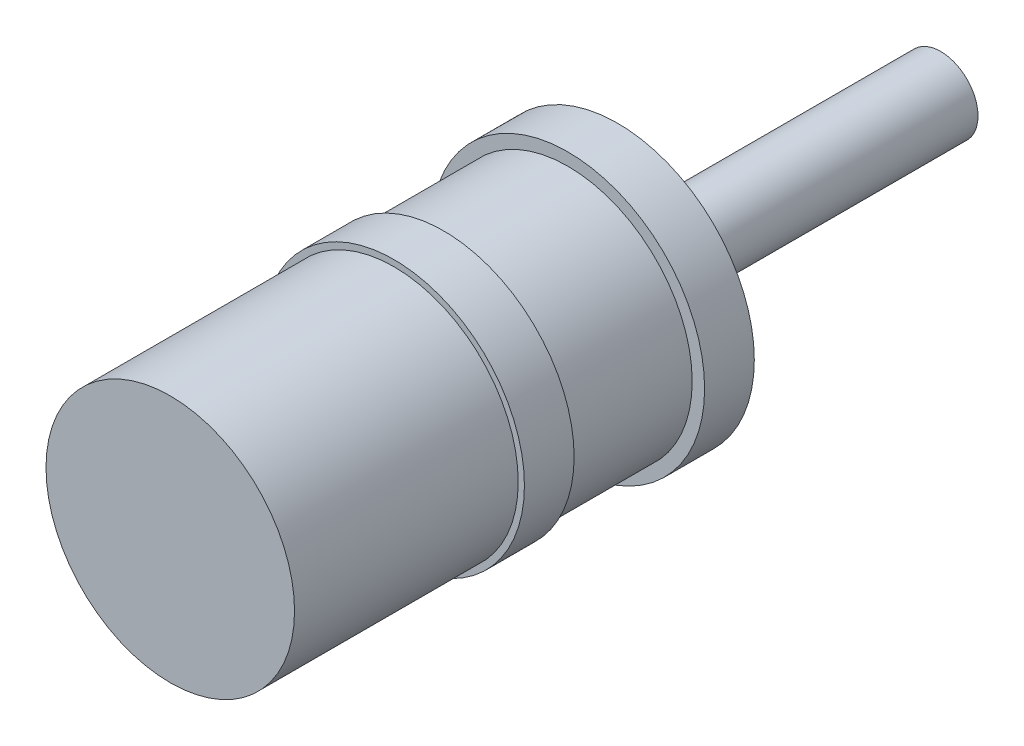
from build123d import *

# Parameters (mm, degrees)
SKETCH_1_R      = 1
SKETCH_1_R_2    = 0.3
EXTRUDE_1_DEPTH = 3.2
SKETCH_1_3_R    = 1.1
SKETCH_1_3_R_2  = 1
SKETCH_1_3_R_3  = 0.3
EXTRUDE_2_DEPTH = 0.4
SKETCH_1_5_R    = 0.3
EXTRUDE_3_DEPTH = 3
SKETCH_2_R      = 1.05
EXTRUDE_4_DEPTH = 0.4


with BuildPart() as part:
    # Sketch 1 → Extrude 1 (new body)
    with BuildSketch(Plane.XY):
        Circle(SKETCH_1_R)
        Circle(SKETCH_1_R_2, mode=Mode.SUBTRACT)
        Circle(SKETCH_1_R_2)
    extrude(amount=EXTRUDE_1_DEPTH)



with BuildPart() as body_2:
    # Sketch 1_3 → Extrude 2 (new body)
    with BuildSketch(Plane.XY):
        Circle(SKETCH_1_3_R)
        Circle(SKETCH_1_3_R_2, mode=Mode.SUBTRACT)
        Circle(SKETCH_1_3_R_2)
        Circle(SKETCH_1_3_R_3, mode=Mode.SUBTRACT)
    extrude(amount=-EXTRUDE_2_DEPTH)


with BuildPart() as part_1:
    add(part.part)

    add(body_2.part)  # Extrude 3 merges body 2
    # Sketch 1_5 → Extrude 3 (add)
    with BuildSketch(Plane.XY):
        Circle(SKETCH_1_5_R)
    extrude(amount=-EXTRUDE_3_DEPTH)

    # Sketch 2 → Extrude 4 (add)
    with BuildSketch(Plane.XY.offset(1)):
        Circle(SKETCH_2_R)
    extrude(amount=EXTRUDE_4_DEPTH)


solid = part_1.part
